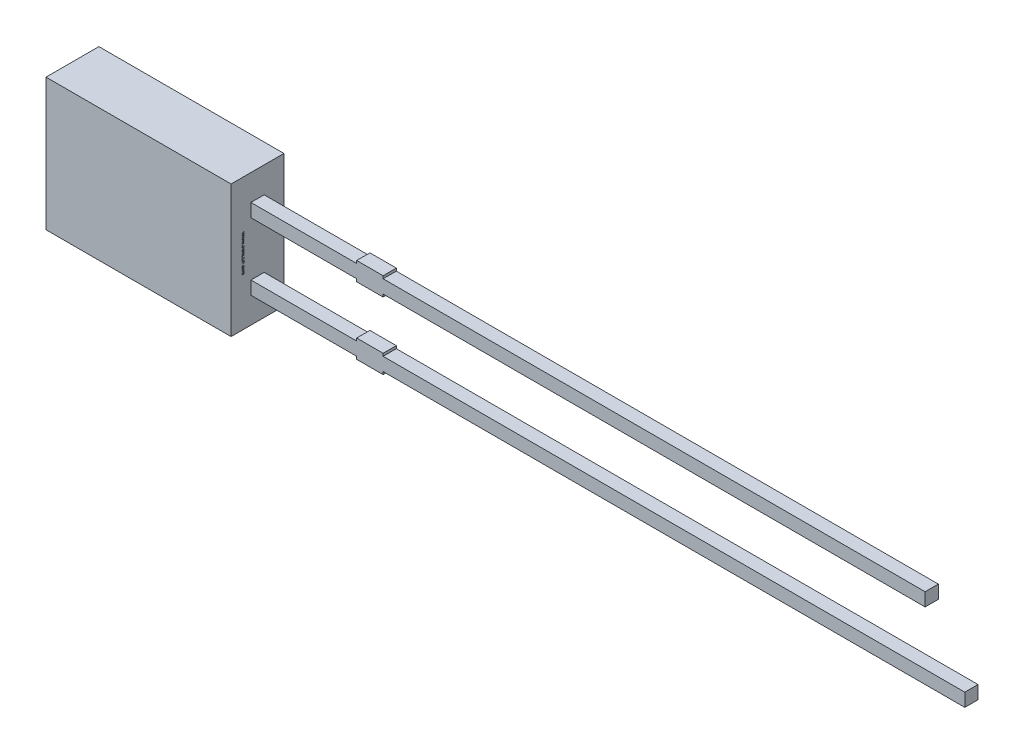
from build123d import *

# Parameters (mm, degrees)
SKETCH1_W          = 7
SKETCH1_H          = 5
EXTRUDE1_DEPTH     = 1
SKETCH1_4_W        = 4
SKETCH1_4_H        = 0.5
SKETCH1_4_W_2      = 1
SKETCH1_4_W_3      = 20.5
SKETCH1_4_H_2      = 0.1
SKETCH1_4_W_4      = 22
EXTRUDE2_DEPTH     = 0.25
SKETCH2_W          = 0.026582279
SKETCH2_H          = 0.025316456
CUT_EXTRUDE1_DEPTH = 0.01


with BuildPart() as part:
    # Sketch1 → Extrude1 (new body, symmetric)
    with BuildSketch(Plane.XY):
        Rectangle(SKETCH1_W, SKETCH1_H)
    extrude(amount=EXTRUDE1_DEPTH, both=True)

    # Sketch1_4 → Extrude2 (add, symmetric)
    with BuildSketch(Plane.XY):
        with Locations((5.5, 1.27)):
            Rectangle(SKETCH1_4_W, SKETCH1_4_H)
        with Locations((8, 1.27)):
            Rectangle(SKETCH1_4_W_2, SKETCH1_4_H)
        with Locations((18.75, 1.27)):
            Rectangle(SKETCH1_4_W_3, SKETCH1_4_H)
        with Locations((8, 1.57)):
            Rectangle(SKETCH1_4_W_2, SKETCH1_4_H_2)
        with Locations((8, 0.97)):
            Rectangle(SKETCH1_4_W_2, SKETCH1_4_H_2)
        with Locations((8, -1.27)):
            Rectangle(SKETCH1_4_W_2, SKETCH1_4_H)
        with Locations((8, -0.97)):
            Rectangle(SKETCH1_4_W_2, SKETCH1_4_H_2)
        with Locations((19.5, -1.27)):
            Rectangle(SKETCH1_4_W_4, SKETCH1_4_H)
        with Locations((5.5, -1.27)):
            Rectangle(SKETCH1_4_W, SKETCH1_4_H)
        with Locations((8, -1.57)):
            Rectangle(SKETCH1_4_W_2, SKETCH1_4_H_2)
    extrude(amount=EXTRUDE2_DEPTH, both=True)

    # Sketch2 → Cut-Extrude1 (cut)
    with BuildSketch(Plane(origin=(3.5, 0, 0), x_dir=(0, 0, -1), z_dir=(1, 0, 0))):
        Polygon((-0.513103718, 0.572151899), (-0.587787263, 0.595609177), (-0.587787263, 0.620352057), (-0.537451029, 0.636768196), (-0.587787263, 0.652294304), (-0.587787263, 0.678026108), (-0.513103718, 0.701265823), (-0.513103718, 0.676087816), (-0.564587104, 0.663093354), (-0.513103718, 0.646677215), (-0.513103718, 0.625178006), (-0.564587104, 0.608860759), (-0.513103718, 0.596044304), align=None)
        Polygon((-0.513103718, 0.437974684), (-0.587787263, 0.461431962), (-0.587787263, 0.486174842), (-0.537451029, 0.502590981), (-0.587787263, 0.518117089), (-0.587787263, 0.543848892), (-0.513103718, 0.567088608), (-0.513103718, 0.541910601), (-0.564587104, 0.528916139), (-0.513103718, 0.5125), (-0.513103718, 0.491000791), (-0.564587104, 0.474683544), (-0.513103718, 0.461867089), align=None)
        Polygon((-0.513103718, 0.303797468), (-0.587787263, 0.327254747), (-0.587787263, 0.351997627), (-0.537451029, 0.368413766), (-0.587787263, 0.383939873), (-0.587787263, 0.409671677), (-0.513103718, 0.432911392), (-0.513103718, 0.407733386), (-0.564587104, 0.394738924), (-0.513103718, 0.378322785), (-0.513103718, 0.356823576), (-0.564587104, 0.340506329), (-0.513103718, 0.327689873), align=None)
        with Locations((-0.574496124, 0.275949367)):
            Rectangle(SKETCH2_W, SKETCH2_H)
        with BuildLine():
            add(Edge.make_bspline(
                [(-0.556616377, 0.159493671), (-0.55783851, 0.159530169), (-0.560238373, 0.15960184), (-0.563746061, 0.160211426), (-0.567070364, 0.161205393), (-0.57023451, 0.162577732), (-0.573203999, 0.164371189), (-0.57600689, 0.16655446), (-0.578611435, 0.169143343), (-0.581047809, 0.172090146), (-0.583229921, 0.175387089), (-0.585135954, 0.178984804), (-0.586730625, 0.18286483), (-0.58806969, 0.187013042), (-0.589058124, 0.191459588), (-0.589782111, 0.196177087), (-0.590255429, 0.201170514), (-0.590297397, 0.204594091), (-0.590318908, 0.206348892)],
                knots=[0, 0, 0, 0, 0.907312236, 1.78165839, 2.635367075, 3.479697475, 4.336364812, 5.205276731, 6.11257575, 7.058770404, 8.040786331, 9.044147278, 10.078219212, 11.153049307, 12.278104542, 13.457648573, 14.696882856, 16, 16, 16, 16], degree=3))
            add(Edge.make_bspline(
                [(-0.590318908, 0.206348892), (-0.590294837, 0.208367148), (-0.590248212, 0.21227633), (-0.589819613, 0.217939855), (-0.589173473, 0.223207892), (-0.588206932, 0.228103607), (-0.587006166, 0.232708206), (-0.585714875, 0.237141474), (-0.584250459, 0.241422786), (-0.583150301, 0.244195876), (-0.582605301, 0.24556962)],
                knots=[0, 0, 0, 0, 1.203215828, 2.33052265, 3.384689099, 4.366106119, 5.303329643, 6.221311756, 7.118865988, 8, 8, 8, 8], degree=3))
            Line((-0.582605301, 0.24556962), (-0.558673339, 0.24556962))
            Line((-0.558673339, 0.24556962), (-0.558673339, 0.242721519))
            add(Edge.make_bspline(
                [(-0.558673339, 0.242721519), (-0.559754794, 0.241356205), (-0.561911355, 0.238633592), (-0.56467396, 0.234200359), (-0.567076123, 0.229552713), (-0.569050124, 0.224707243), (-0.570636449, 0.219810398), (-0.571729976, 0.21493502), (-0.572477325, 0.210169433), (-0.572557831, 0.207010864), (-0.572597389, 0.205458861)],
                knots=[0, 0, 0, 0, 1.030622468, 2.055194264, 3.087043286, 4.125157485, 5.149848264, 6.130935704, 7.081611712, 8, 8, 8, 8], degree=3))
            add(Edge.make_bspline(
                [(-0.572597389, 0.205458861), (-0.572596495, 0.205030082), (-0.57259458, 0.2041121), (-0.572465737, 0.202644063), (-0.572372573, 0.200985464), (-0.572163356, 0.199206598), (-0.571944772, 0.197415781), (-0.571564452, 0.195761121), (-0.571202614, 0.194257482), (-0.570834436, 0.193351), (-0.570659098, 0.192919304)],
                knots=[0, 0, 0, 0, 0.806378557, 1.726393851, 2.771014456, 3.931269413, 5.096090628, 6.161710732, 7.124547685, 8, 8, 8, 8], degree=3))
            add(Edge.make_bspline(
                [(-0.570659098, 0.192919304), (-0.570431274, 0.192439517), (-0.569983552, 0.191496634), (-0.569165945, 0.190201714), (-0.568294644, 0.189019042), (-0.567329225, 0.187957582), (-0.566151316, 0.187107314), (-0.56475046, 0.186479113), (-0.56310016, 0.186136019), (-0.561925149, 0.186096725), (-0.561303877, 0.186075949)],
                knots=[0, 0, 0, 0, 1.024407818, 2.013179384, 2.949802342, 3.859052226, 4.77034807, 5.732977883, 6.801339628, 8, 8, 8, 8], degree=3))
            add(Edge.make_bspline(
                [(-0.561303877, 0.186075949), (-0.560757981, 0.186107391), (-0.559684588, 0.186169215), (-0.558156592, 0.186751006), (-0.556734715, 0.187633905), (-0.555473999, 0.188920927), (-0.554316561, 0.190515003), (-0.553346264, 0.19247074), (-0.552466191, 0.194723719), (-0.552048922, 0.196368178), (-0.551829984, 0.197231013)],
                knots=[0, 0, 0, 0, 0.825212765, 1.622611382, 2.449701629, 3.348069183, 4.336544339, 5.428209675, 6.6506027, 8, 8, 8, 8], degree=3))
            add(Edge.make_bspline(
                [(-0.551829984, 0.197231013), (-0.551382244, 0.19919974), (-0.550465054, 0.203232648), (-0.549317947, 0.209380757), (-0.548051874, 0.215510984), (-0.546842333, 0.219469696), (-0.546252453, 0.221400316)],
                knots=[0, 0, 0, 0, 0.976104583, 1.999535498, 3.024395274, 4, 4, 4, 4], degree=3))
            add(Edge.make_bspline(
                [(-0.546252453, 0.221400316), (-0.54589946, 0.222438832), (-0.545212327, 0.224460401), (-0.544050702, 0.227351945), (-0.54278075, 0.230013057), (-0.541425618, 0.232453168), (-0.53995162, 0.23465249), (-0.538418231, 0.236647679), (-0.536764394, 0.238391205), (-0.535032474, 0.239938889), (-0.533180471, 0.241262203), (-0.531236335, 0.242416954), (-0.529175869, 0.243392589), (-0.527014581, 0.244201473), (-0.524735712, 0.244818545), (-0.522358839, 0.245239801), (-0.519875479, 0.24553819), (-0.518181125, 0.245559001), (-0.517316535, 0.24556962)],
                knots=[0, 0, 0, 0, 1.287286806, 2.505824366, 3.654938963, 4.74627059, 5.778586806, 6.75996495, 7.696030012, 8.595059759, 9.482019644, 10.363222407, 11.245851011, 12.154256429, 13.068444161, 14.012503255, 14.985824751, 16, 16, 16, 16], degree=3))
            add(Edge.make_bspline(
                [(-0.517316535, 0.24556962), (-0.51616039, 0.245532318), (-0.513885118, 0.245458909), (-0.510556074, 0.24485748), (-0.507407337, 0.24383089), (-0.504403874, 0.242444827), (-0.501590788, 0.240616199), (-0.49891224, 0.238431404), (-0.496440649, 0.235807357), (-0.494140315, 0.232830235), (-0.492060917, 0.229542851), (-0.49023036, 0.226003867), (-0.488693709, 0.222234578), (-0.487419815, 0.218249032), (-0.486465144, 0.214030563), (-0.485746212, 0.20959333), (-0.485333031, 0.204919541), (-0.48528178, 0.20172812), (-0.485255617, 0.200098892)],
                knots=[0, 0, 0, 0, 0.894990994, 1.761326291, 2.609044902, 3.454222546, 4.315366365, 5.200560057, 6.125081389, 7.100429509, 8.110379559, 9.133447974, 10.182136699, 11.259192205, 12.370181258, 13.528580438, 14.738335141, 16, 16, 16, 16], degree=3))
            add(Edge.make_bspline(
                [(-0.485255617, 0.200098892), (-0.485277809, 0.198430205), (-0.485322154, 0.19509566), (-0.485700132, 0.190114218), (-0.48625536, 0.185153716), (-0.487097065, 0.180289886), (-0.488073482, 0.175599331), (-0.489169278, 0.171186095), (-0.490407242, 0.167106634), (-0.491361587, 0.16453297), (-0.491822073, 0.163291139)],
                knots=[0, 0, 0, 0, 1.065403572, 2.129000689, 3.188532477, 4.251604565, 5.279552602, 6.247508681, 7.154397237, 8, 8, 8, 8], degree=3))
            Line((-0.491822073, 0.163291139), (-0.514369541, 0.163291139))
            Line((-0.514369541, 0.163291139), (-0.514369541, 0.166119462))
            add(Edge.make_bspline(
                [(-0.514369541, 0.166119462), (-0.513569195, 0.167192367), (-0.511932465, 0.169386485), (-0.509848792, 0.173046122), (-0.507890927, 0.177004358), (-0.506206768, 0.181283188), (-0.504747286, 0.185742216), (-0.503728121, 0.190325174), (-0.503086311, 0.194951338), (-0.503013536, 0.198053049), (-0.502977136, 0.19960443)],
                knots=[0, 0, 0, 0, 0.892283326, 1.824742884, 2.804416662, 3.836872171, 4.8899239, 5.931447339, 6.965372909, 8, 8, 8, 8], degree=3))
            add(Edge.make_bspline(
                [(-0.502977136, 0.19960443), (-0.502998588, 0.200700098), (-0.503041491, 0.202891315), (-0.503432175, 0.206159523), (-0.504063069, 0.209401584), (-0.50488235, 0.211442107), (-0.505291218, 0.212460443)],
                knots=[0, 0, 0, 0, 0.999146175, 1.998183711, 3.000980573, 4, 4, 4, 4], degree=3))
            add(Edge.make_bspline(
                [(-0.505291218, 0.212460443), (-0.505492685, 0.212893946), (-0.505895484, 0.213760664), (-0.506668048, 0.214967308), (-0.507596859, 0.216071977), (-0.508648852, 0.217064055), (-0.509805225, 0.217932452), (-0.511080051, 0.218547803), (-0.512442966, 0.218923676), (-0.513378197, 0.218965835), (-0.513855301, 0.218987342)],
                knots=[0, 0, 0, 0, 1.00524851, 2.009826503, 3.004679593, 4.035271301, 5.048246368, 6.034938417, 6.997532266, 8, 8, 8, 8], degree=3))
            add(Edge.make_bspline(
                [(-0.513855301, 0.218987342), (-0.514493466, 0.218952904), (-0.515712942, 0.218887095), (-0.517428738, 0.218280511), (-0.518907172, 0.217295678), (-0.519902092, 0.216135073), (-0.52059953, 0.215017943), (-0.52111004, 0.213982284), (-0.521593399, 0.212773057), (-0.522090867, 0.211401809), (-0.522582055, 0.209865482), (-0.523057602, 0.208156925), (-0.523506897, 0.206274208), (-0.523793088, 0.204958333), (-0.523942326, 0.204272152)],
                knots=[0, 0, 0, 0, 1.173816843, 2.243057204, 3.312297565, 4.415174738, 5.03266065, 5.73970059, 6.541434878, 7.433956553, 8.430083051, 9.515931566, 10.70464786, 12, 12, 12, 12], degree=3))
            add(Edge.make_bspline(
                [(-0.523942326, 0.204272152), (-0.524318388, 0.202439363), (-0.525057265, 0.198838337), (-0.526160754, 0.193437153), (-0.527435723, 0.18793438), (-0.528584526, 0.184269053), (-0.529183623, 0.182357595)],
                knots=[0, 0, 0, 0, 0.995744513, 1.956417928, 2.934277412, 4, 4, 4, 4], degree=3))
            add(Edge.make_bspline(
                [(-0.529183623, 0.182357595), (-0.529502867, 0.181411041), (-0.53012736, 0.179559428), (-0.531213643, 0.176918797), (-0.532387625, 0.174471738), (-0.533629157, 0.172204706), (-0.534973123, 0.170130736), (-0.53639577, 0.168236053), (-0.537922679, 0.166552235), (-0.539535906, 0.16505467), (-0.541246007, 0.16373551), (-0.543085079, 0.162603212), (-0.545033882, 0.161630984), (-0.547120082, 0.160861379), (-0.549314669, 0.160243358), (-0.551646036, 0.159820261), (-0.554090413, 0.159526278), (-0.55576499, 0.159504661), (-0.556616377, 0.159493671)],
                knots=[0, 0, 0, 0, 1.237467875, 2.420686895, 3.535046182, 4.599015201, 5.620884487, 6.594603852, 7.531477383, 8.433220087, 9.318759595, 10.202828513, 11.105163009, 12.01247538, 12.953896178, 13.926381251, 14.945733412, 16, 16, 16, 16], degree=3))
        make_face()
        with BuildLine():
            Line((-0.587787263, 0.067088608), (-0.587787263, 0.091139241))
            Line((-0.587787263, 0.091139241), (-0.579954984, 0.091139241))
            add(Edge.make_bspline(
                [(-0.579954984, 0.091139241), (-0.580763543, 0.092232549), (-0.582322431, 0.094340433), (-0.584402649, 0.097513458), (-0.586177915, 0.100539548), (-0.587737135, 0.103453039), (-0.588912521, 0.106475242), (-0.589740587, 0.109706756), (-0.59024036, 0.113209581), (-0.590292144, 0.115636475), (-0.590318908, 0.116890823)],
                knots=[0, 0, 0, 0, 1.150872466, 2.218865267, 3.209461834, 4.120482262, 5.012764827, 5.946708227, 6.938749913, 8, 8, 8, 8], degree=3))
            add(Edge.make_bspline(
                [(-0.590318908, 0.116890823), (-0.590296189, 0.117907175), (-0.590251949, 0.119886305), (-0.589907071, 0.122763545), (-0.58936942, 0.125471173), (-0.588561829, 0.127986213), (-0.587596026, 0.130350202), (-0.586316068, 0.132487752), (-0.584885893, 0.134491354), (-0.583178848, 0.136273026), (-0.581281115, 0.137888648), (-0.579148654, 0.139271198), (-0.576815729, 0.140448909), (-0.574263875, 0.141390006), (-0.571505572, 0.142145096), (-0.568526324, 0.142669028), (-0.565339196, 0.142989621), (-0.563144066, 0.14302156), (-0.562015902, 0.143037975)],
                knots=[0, 0, 0, 0, 1.109008058, 2.159558935, 3.158726032, 4.116861086, 5.039058877, 5.938775559, 6.82970133, 7.720510853, 8.624361809, 9.544451588, 10.487360536, 11.471068125, 12.508000841, 13.604731202, 14.768976642, 16, 16, 16, 16], degree=3))
            Line((-0.562015902, 0.143037975), (-0.513103718, 0.143037975))
            Line((-0.513103718, 0.143037975), (-0.513103718, 0.118987342))
            Line((-0.513103718, 0.118987342), (-0.550682832, 0.118987342))
            add(Edge.make_bspline(
                [(-0.550682832, 0.118987342), (-0.551599303, 0.118985706), (-0.553353519, 0.118982576), (-0.555859325, 0.118900237), (-0.558127498, 0.118779336), (-0.560169527, 0.118640631), (-0.562016277, 0.118387615), (-0.563682439, 0.118009906), (-0.56520204, 0.11753908), (-0.566108742, 0.117074761), (-0.566545174, 0.116851266)],
                knots=[0, 0, 0, 0, 1.361401701, 2.605856924, 3.723918663, 4.735739235, 5.645738665, 6.489217889, 7.27279937, 8, 8, 8, 8], degree=3))
            add(Edge.make_bspline(
                [(-0.566545174, 0.116851266), (-0.566943889, 0.116621259), (-0.567727728, 0.116169086), (-0.568733906, 0.115248796), (-0.569578174, 0.114170053), (-0.570234203, 0.112892449), (-0.570733151, 0.111405901), (-0.571073388, 0.109677971), (-0.57128889, 0.107692609), (-0.571316798, 0.106283591), (-0.571331566, 0.105537975)],
                knots=[0, 0, 0, 0, 0.849138082, 1.669332372, 2.503455908, 3.370611167, 4.311442699, 5.394692208, 6.621337967, 8, 8, 8, 8], degree=3))
            add(Edge.make_bspline(
                [(-0.571331566, 0.105537975), (-0.571314209, 0.104996691), (-0.571278522, 0.103883773), (-0.571046076, 0.102172461), (-0.570689401, 0.100375884), (-0.570029546, 0.097861301), (-0.568843367, 0.094694674), (-0.567488959, 0.092335372), (-0.566802294, 0.091139241)],
                knots=[0, 0, 0, 0, 0.638127216, 1.312033637, 2.033062677, 2.79661882, 4.375931797, 6, 6, 6, 6], degree=3))
            Line((-0.566802294, 0.091139241), (-0.513103718, 0.091139241))
            Line((-0.513103718, 0.091139241), (-0.513103718, 0.067088608))
            Line((-0.513103718, 0.067088608), (-0.587787263, 0.067088608))
        make_face()
        with BuildLine():
            Line((-0.587787263, -0.030379747), (-0.587787263, -0.006329114))
            Line((-0.587787263, -0.006329114), (-0.550208149, -0.006329114))
            add(Edge.make_bspline(
                [(-0.550208149, -0.006329114), (-0.548678106, -0.0063046), (-0.545627081, -0.006255716), (-0.54186467, -0.005973592), (-0.539022346, -0.00559507), (-0.537184465, -0.005225415), (-0.535636325, -0.004793715), (-0.534750566, -0.004381435), (-0.534345807, -0.004193038)],
                knots=[0, 0, 0, 0, 1.709124929, 3.408128882, 4.211124727, 4.91016634, 5.501986363, 6, 6, 6, 6], degree=3))
            add(Edge.make_bspline(
                [(-0.534345807, -0.004193038), (-0.533947754, -0.003948575), (-0.533167314, -0.003469272), (-0.532154301, -0.002531948), (-0.53132546, -0.001438061), (-0.530643909, -0.000167292), (-0.530173329, 0.001323905), (-0.529780099, 0.003040645), (-0.52961319, 0.005027263), (-0.52957803, 0.006434533), (-0.529559415, 0.007179589)],
                knots=[0, 0, 0, 0, 0.86006424, 1.686277094, 2.52783008, 3.38194165, 4.331801563, 5.402842185, 6.624978739, 8, 8, 8, 8], degree=3))
            add(Edge.make_bspline(
                [(-0.529559415, 0.007179589), (-0.529616152, 0.00831141), (-0.529732005, 0.010622505), (-0.530443513, 0.013484698), (-0.531262472, 0.015815302), (-0.532021303, 0.017667827), (-0.532992744, 0.019576457), (-0.533714567, 0.020855869), (-0.534088687, 0.021518987)],
                knots=[0, 0, 0, 0, 1.338371478, 2.732853438, 3.468019217, 4.261884641, 5.099136535, 6, 6, 6, 6], degree=3))
            Line((-0.534088687, 0.021518987), (-0.587787263, 0.021518987))
            Line((-0.587787263, 0.021518987), (-0.587787263, 0.04556962))
            Line((-0.587787263, 0.04556962), (-0.513103718, 0.04556962))
            Line((-0.513103718, 0.04556962), (-0.513103718, 0.021518987))
            Line((-0.513103718, 0.021518987), (-0.520935997, 0.021518987))
            add(Edge.make_bspline(
                [(-0.520935997, 0.021518987), (-0.520129845, 0.020461581), (-0.518560623, 0.018403276), (-0.516520203, 0.015224038), (-0.514721433, 0.01214014), (-0.513208617, 0.009087131), (-0.512001842, 0.005972176), (-0.511190853, 0.002709417), (-0.51064705, -0.000706989), (-0.510597356, -0.003043704), (-0.510572073, -0.004232595)],
                knots=[0, 0, 0, 0, 1.126119141, 2.192057864, 3.198061997, 4.149848529, 5.076251285, 6.021887753, 6.99356175, 8, 8, 8, 8], degree=3))
            add(Edge.make_bspline(
                [(-0.510572073, -0.004232595), (-0.510597462, -0.005228866), (-0.510647026, -0.007173765), (-0.510956735, -0.010008526), (-0.5115074, -0.012679947), (-0.512305229, -0.015172221), (-0.513290841, -0.017514841), (-0.514522356, -0.019676785), (-0.515980779, -0.021668856), (-0.517641782, -0.023497257), (-0.519531508, -0.025128075), (-0.521648772, -0.026545111), (-0.523991869, -0.027725092), (-0.526552178, -0.028695805), (-0.529317287, -0.029470228), (-0.532313252, -0.029985359), (-0.535517431, -0.030339143), (-0.537733474, -0.030365941), (-0.538875079, -0.030379747)],
                knots=[0, 0, 0, 0, 1.08848837, 2.124922927, 3.110950502, 4.063144162, 4.979605775, 5.882838355, 6.774625441, 7.671951181, 8.57587277, 9.494821853, 10.448322275, 11.435533005, 12.482327682, 13.580118324, 14.753386918, 16, 16, 16, 16], degree=3))
            Line((-0.538875079, -0.030379747), (-0.587787263, -0.030379747))
        make_face()
        Polygon((-0.587787263, -0.125316456), (-0.587787263, -0.053164557), (-0.487787263, -0.053164557), (-0.487787263, -0.078481013), (-0.568799921, -0.078481013), (-0.568799921, -0.125316456), align=None)
        Polygon((-0.587787263, -0.212658228), (-0.587787263, -0.140506329), (-0.487787263, -0.140506329), (-0.487787263, -0.212658228), (-0.506774604, -0.212658228), (-0.506774604, -0.165822785), (-0.524496123, -0.165822785), (-0.524496123, -0.208860759), (-0.543483465, -0.208860759), (-0.543483465, -0.165822785), (-0.568799921, -0.165822785), (-0.568799921, -0.212658228), align=None)
        with BuildLine():
            add(Edge.make_bspline(
                [(-0.537886155, -0.329113924), (-0.539033844, -0.329094609), (-0.54130673, -0.329056357), (-0.544671537, -0.328761165), (-0.547937212, -0.32823514), (-0.551121461, -0.327555959), (-0.554200388, -0.326633453), (-0.557207965, -0.325551739), (-0.560113459, -0.324242093), (-0.562914893, -0.322737241), (-0.565586996, -0.321087768), (-0.568107205, -0.319313019), (-0.570490423, -0.31746724), (-0.572685317, -0.315477927), (-0.574727336, -0.313398746), (-0.576618151, -0.311223217), (-0.578321581, -0.308918153), (-0.579344466, -0.30731099), (-0.579856092, -0.30650712)],
                knots=[0, 0, 0, 0, 1.105570398, 2.18947457, 3.250358341, 4.290584537, 5.323553275, 6.344225964, 7.367641686, 8.3905646, 9.405808457, 10.390761353, 11.358902336, 12.307789878, 13.241960776, 14.165076779, 15.082208636, 16, 16, 16, 16], degree=3))
            add(Edge.make_bspline(
                [(-0.579856092, -0.30650712), (-0.580568231, -0.305267892), (-0.581996144, -0.302783112), (-0.583664734, -0.298799278), (-0.58506885, -0.294673795), (-0.586123275, -0.290323409), (-0.586850319, -0.285676399), (-0.587411125, -0.28067499), (-0.587712885, -0.275267401), (-0.587761905, -0.271532506), (-0.587787263, -0.269600475)],
                knots=[0, 0, 0, 0, 0.896288622, 1.797150563, 2.705281913, 3.629615989, 4.602417572, 5.655716007, 6.787320449, 8, 8, 8, 8], degree=3))
            Line((-0.587787263, -0.269600475), (-0.587787263, -0.234177215))
            Line((-0.587787263, -0.234177215), (-0.487787263, -0.234177215))
            Line((-0.487787263, -0.234177215), (-0.487787263, -0.270609177))
            add(Edge.make_bspline(
                [(-0.487787263, -0.270609177), (-0.487803874, -0.272587909), (-0.487835914, -0.276404637), (-0.488253505, -0.281921476), (-0.488850329, -0.287026684), (-0.4897752, -0.291712032), (-0.490890545, -0.296012037), (-0.492249673, -0.299937513), (-0.493748381, -0.303549287), (-0.495022074, -0.305728129), (-0.49563932, -0.306784019)],
                knots=[0, 0, 0, 0, 1.267175336, 2.444223962, 3.542125549, 4.557526608, 5.500936977, 6.385043188, 7.217374394, 8, 8, 8, 8], degree=3))
            add(Edge.make_bspline(
                [(-0.49563932, -0.306784019), (-0.49617586, -0.307634972), (-0.497242774, -0.309327097), (-0.499024626, -0.311728312), (-0.500980703, -0.313957739), (-0.503032522, -0.316086242), (-0.505235409, -0.318066059), (-0.507574116, -0.319909259), (-0.51005221, -0.321613076), (-0.512661679, -0.323171039), (-0.515391731, -0.324591854), (-0.51826479, -0.32578116), (-0.52124332, -0.326830509), (-0.524352282, -0.327636046), (-0.527560119, -0.32833396), (-0.530901463, -0.328768694), (-0.534353951, -0.329055305), (-0.536698841, -0.32909422), (-0.537886155, -0.329113924)],
                knots=[0, 0, 0, 0, 0.964065863, 1.917049184, 2.86229036, 3.805247319, 4.749389377, 5.698846072, 6.657678277, 7.629829384, 8.610569287, 9.604676042, 10.607940105, 11.6349849, 12.681042988, 13.752616828, 14.862056989, 16, 16, 16, 16], degree=3))
        make_face()
        with BuildLine():
            add(Edge.make_bspline(
                [(-0.537727927, -0.302531646), (-0.536923167, -0.302521405), (-0.535344583, -0.302501317), (-0.533029069, -0.30230975), (-0.530799419, -0.302050694), (-0.528664727, -0.30161964), (-0.526605156, -0.301119993), (-0.524647662, -0.300477843), (-0.522768089, -0.299753447), (-0.5209906, -0.298871809), (-0.519282218, -0.297898172), (-0.517696702, -0.296750679), (-0.516183816, -0.295502341), (-0.514755832, -0.294124054), (-0.513449936, -0.292581114), (-0.512219859, -0.290921012), (-0.511091533, -0.289120654), (-0.510431484, -0.287847665), (-0.510097389, -0.287203323)],
                knots=[0, 0, 0, 0, 1.152093354, 2.259898929, 3.325467225, 4.364140538, 5.376172865, 6.358396836, 7.312077728, 8.257828931, 9.196960457, 10.124297759, 11.056236784, 12.004246951, 12.961658638, 13.947279359, 14.960983522, 16, 16, 16, 16], degree=3))
            add(Edge.make_bspline(
                [(-0.510097389, -0.287203323), (-0.509790677, -0.286528425), (-0.509182753, -0.285190731), (-0.50845156, -0.283119908), (-0.507878725, -0.281030524), (-0.507447866, -0.278828925), (-0.507125936, -0.276359165), (-0.506928677, -0.273433583), (-0.506786508, -0.269977674), (-0.506778756, -0.267490959), (-0.506774604, -0.266159019)],
                knots=[0, 0, 0, 0, 0.826967603, 1.639107464, 2.447640171, 3.242670507, 4.14065217, 5.225198036, 6.513753944, 8, 8, 8, 8], degree=3))
            Line((-0.506774604, -0.266159019), (-0.506774604, -0.259493671))
            Line((-0.506774604, -0.259493671), (-0.568799921, -0.259493671))
            Line((-0.568799921, -0.259493671), (-0.568799921, -0.266159019))
            add(Edge.make_bspline(
                [(-0.568799921, -0.266159019), (-0.568795171, -0.266917226), (-0.568786002, -0.268380991), (-0.568742939, -0.270497235), (-0.568696052, -0.272463031), (-0.56857959, -0.274267902), (-0.568506944, -0.275926587), (-0.568328565, -0.277413368), (-0.568186385, -0.278755857), (-0.567918662, -0.280323454), (-0.567502479, -0.28217662), (-0.5668243, -0.28433788), (-0.565973904, -0.286478414), (-0.565288937, -0.287866987), (-0.564943117, -0.288568038)],
                knots=[0, 0, 0, 0, 1.186793418, 2.291178421, 3.313283093, 4.264083014, 5.122158624, 5.910777728, 6.607099052, 7.234812932, 8.398911528, 9.577194775, 10.776795607, 12, 12, 12, 12], degree=3))
            add(Edge.make_bspline(
                [(-0.564943117, -0.288568038), (-0.564601601, -0.289153154), (-0.563928086, -0.29030708), (-0.562794013, -0.291930584), (-0.561586288, -0.293438302), (-0.560297837, -0.294834314), (-0.558909595, -0.296097614), (-0.557443054, -0.297249633), (-0.555895075, -0.298280082), (-0.553701558, -0.299515471), (-0.550670621, -0.300738716), (-0.546703235, -0.301778259), (-0.542343471, -0.30241513), (-0.539305854, -0.302491812), (-0.537727927, -0.302531646)],
                knots=[0, 0, 0, 0, 0.755160452, 1.489275589, 2.205657296, 2.907868421, 3.605098304, 4.296256403, 4.985378686, 5.676536785, 7.100390329, 8.614249252, 10.241231541, 12, 12, 12, 12], degree=3))
        make_face(mode=Mode.SUBTRACT)
        with Locations((-0.574496124, -0.360759494)):
            Rectangle(SKETCH2_W, SKETCH2_H)
        with BuildLine():
            add(Edge.make_bspline(
                [(-0.590318908, -0.435403481), (-0.590297097, -0.433813368), (-0.590254285, -0.430692232), (-0.589777368, -0.42612089), (-0.589059673, -0.421755717), (-0.588038767, -0.417609409), (-0.58669127, -0.413695618), (-0.585038335, -0.41003198), (-0.58305315, -0.406625123), (-0.581473941, -0.404566476), (-0.580686788, -0.403540348)],
                knots=[0, 0, 0, 0, 1.123670284, 2.205584497, 3.245308791, 4.249063313, 5.220352711, 6.167273909, 7.086481357, 8, 8, 8, 8], degree=3))
            add(Edge.make_bspline(
                [(-0.580686788, -0.403540348), (-0.579832014, -0.402588601), (-0.578125771, -0.400688786), (-0.575154344, -0.398222853), (-0.5718713, -0.396099767), (-0.568269078, -0.394314215), (-0.564352349, -0.392883291), (-0.560107686, -0.391860157), (-0.555546906, -0.391240912), (-0.552398972, -0.391173746), (-0.550781725, -0.391139241)],
                knots=[0, 0, 0, 0, 0.916457077, 1.82937027, 2.759194969, 3.714948755, 4.706655623, 5.743329475, 6.840637961, 8, 8, 8, 8], degree=3))
            add(Edge.make_bspline(
                [(-0.550781725, -0.391139241), (-0.549078498, -0.391178001), (-0.545777417, -0.391253124), (-0.54100523, -0.391916883), (-0.536587549, -0.392986496), (-0.532535641, -0.394524054), (-0.52884245, -0.396454496), (-0.525470615, -0.398718989), (-0.522427691, -0.401339514), (-0.520682251, -0.403346653), (-0.519808623, -0.404351266)],
                knots=[0, 0, 0, 0, 1.171797512, 2.271099083, 3.308930235, 4.294129479, 5.24602549, 6.17106565, 7.084581485, 8, 8, 8, 8], degree=3))
            add(Edge.make_bspline(
                [(-0.519808623, -0.404351266), (-0.519040037, -0.405377136), (-0.517493581, -0.407441268), (-0.515592881, -0.410844773), (-0.513998096, -0.414467988), (-0.512750451, -0.418297559), (-0.511796545, -0.422270367), (-0.511072702, -0.426330027), (-0.510652144, -0.43047628), (-0.510598892, -0.43326648), (-0.510572073, -0.434671677)],
                knots=[0, 0, 0, 0, 0.952130878, 1.915761808, 2.890227217, 3.891541892, 4.905612075, 5.925811839, 6.955400088, 8, 8, 8, 8], degree=3))
            add(Edge.make_bspline(
                [(-0.510572073, -0.434671677), (-0.510589075, -0.435918396), (-0.510622507, -0.438369867), (-0.510944617, -0.441970914), (-0.511477736, -0.445425455), (-0.512216338, -0.448730387), (-0.513107941, -0.451904334), (-0.514147083, -0.454954511), (-0.515280351, -0.457914321), (-0.516164886, -0.45981489), (-0.51660451, -0.460759494)],
                knots=[0, 0, 0, 0, 1.107648782, 2.178012834, 3.209595929, 4.211695017, 5.185427128, 6.137685403, 7.07440854, 8, 8, 8, 8], degree=3))
            Line((-0.51660451, -0.460759494), (-0.537154351, -0.460759494))
            Line((-0.537154351, -0.460759494), (-0.537154351, -0.45741693))
            add(Edge.make_bspline(
                [(-0.537154351, -0.45741693), (-0.536737131, -0.456917386), (-0.535835417, -0.45583775), (-0.534414665, -0.454051335), (-0.532885071, -0.451902393), (-0.531993125, -0.450248857), (-0.531517484, -0.449367089)],
                knots=[0, 0, 0, 0, 0.792826818, 1.713491785, 2.780691913, 4, 4, 4, 4], degree=3))
            add(Edge.make_bspline(
                [(-0.531517484, -0.449367089), (-0.531075526, -0.448439154), (-0.530169666, -0.446537209), (-0.529336833, -0.443981204), (-0.528769106, -0.441789202), (-0.528512685, -0.439971666), (-0.528323123, -0.438038046), (-0.528303617, -0.436702803), (-0.528293592, -0.436016614)],
                knots=[0, 0, 0, 0, 1.332524827, 2.731214173, 3.480270227, 4.267952375, 5.109889624, 6, 6, 6, 6], degree=3))
            add(Edge.make_bspline(
                [(-0.528293592, -0.436016614), (-0.528313141, -0.435251058), (-0.528351028, -0.433767448), (-0.528628083, -0.431605939), (-0.529106342, -0.429587528), (-0.529746442, -0.427684306), (-0.530634055, -0.425946243), (-0.531667692, -0.424319403), (-0.532893493, -0.422827143), (-0.534334436, -0.421507882), (-0.535914365, -0.420315156), (-0.53764848, -0.419295954), (-0.539495079, -0.418383498), (-0.541499528, -0.41768856), (-0.543628304, -0.417128822), (-0.545891424, -0.416739892), (-0.548290934, -0.416497934), (-0.549937242, -0.416470016), (-0.550781725, -0.416455696)],
                knots=[0, 0, 0, 0, 1.087302107, 2.107140881, 3.088415001, 4.030197574, 4.951552271, 5.852940509, 6.764198256, 7.685219758, 8.621679636, 9.570836121, 10.538340132, 11.542450476, 12.578202196, 13.66207107, 14.800746211, 16, 16, 16, 16], degree=3))
            add(Edge.make_bspline(
                [(-0.550781725, -0.416455696), (-0.551645881, -0.416470471), (-0.553324894, -0.416499177), (-0.555766505, -0.416732691), (-0.558047936, -0.417148582), (-0.560173256, -0.41771983), (-0.562139274, -0.418444178), (-0.563936671, -0.419349295), (-0.565593478, -0.420385652), (-0.56705609, -0.42163021), (-0.568372411, -0.422994093), (-0.569508546, -0.424508985), (-0.570456691, -0.426168224), (-0.571261154, -0.427950405), (-0.571839552, -0.429883445), (-0.572276244, -0.431939982), (-0.572564801, -0.434129537), (-0.572586363, -0.435639891), (-0.572597389, -0.436412184)],
                knots=[0, 0, 0, 0, 1.230336593, 2.390482092, 3.487897344, 4.52859895, 5.520747884, 6.465347575, 7.38981449, 8.296085817, 9.192433006, 10.084246191, 10.984321635, 11.908883871, 12.862027947, 13.850751296, 14.901019963, 16, 16, 16, 16], degree=3))
            add(Edge.make_bspline(
                [(-0.572597389, -0.436412184), (-0.572589262, -0.437138038), (-0.572573417, -0.438553063), (-0.57235534, -0.44061781), (-0.572079458, -0.442578718), (-0.57164005, -0.444414258), (-0.571097675, -0.446109524), (-0.570531169, -0.447669947), (-0.569926384, -0.449082395), (-0.56945883, -0.449943749), (-0.569235048, -0.450356013)],
                knots=[0, 0, 0, 0, 1.200823684, 2.340960236, 3.433630075, 4.476504061, 5.46014544, 6.378484521, 7.223905657, 8, 8, 8, 8], degree=3))
            add(Edge.make_bspline(
                [(-0.569235048, -0.450356013), (-0.568805153, -0.451056218), (-0.567973511, -0.452410785), (-0.566571945, -0.454249513), (-0.565157685, -0.455894382), (-0.564201468, -0.456918894), (-0.56373663, -0.45741693)],
                knots=[0, 0, 0, 0, 1.098601379, 2.125273733, 3.088655601, 4, 4, 4, 4], degree=3))
            Line((-0.56373663, -0.45741693), (-0.56373663, -0.460759494))
            Line((-0.56373663, -0.460759494), (-0.584444699, -0.460759494))
            add(Edge.make_bspline(
                [(-0.584444699, -0.460759494), (-0.584882194, -0.459814104), (-0.585757287, -0.457923097), (-0.586911159, -0.455008518), (-0.587879319, -0.452020545), (-0.5887824, -0.448972172), (-0.589470762, -0.445800089), (-0.589963885, -0.442477058), (-0.590264797, -0.43899556), (-0.590300625, -0.436617171), (-0.590318908, -0.435403481)],
                knots=[0, 0, 0, 0, 0.952012952, 1.904254716, 2.862729541, 3.822037426, 4.808956931, 5.82647221, 6.890850784, 8, 8, 8, 8], degree=3))
        make_face()
        with BuildLine():
            add(Edge.make_bspline(
                [(-0.550485048, -0.553164557), (-0.551989954, -0.553139862), (-0.554923419, -0.553091723), (-0.559195211, -0.552552407), (-0.563231208, -0.551739627), (-0.567018417, -0.550567096), (-0.570575691, -0.549086703), (-0.573865484, -0.547235764), (-0.576918714, -0.545064759), (-0.579708598, -0.542573722), (-0.582207109, -0.53977252), (-0.584402362, -0.536698338), (-0.586215804, -0.533324511), (-0.587727894, -0.5297102), (-0.588897129, -0.525825548), (-0.589709846, -0.521671329), (-0.590245317, -0.517254195), (-0.590293969, -0.514215776), (-0.590318908, -0.512658228)],
                knots=[0, 0, 0, 0, 1.120167703, 2.183507516, 3.201345984, 4.182878364, 5.131270247, 6.065524964, 6.98789854, 7.91635504, 8.84481154, 9.778033504, 10.722808862, 11.691211189, 12.691525459, 13.738229926, 14.840575679, 16, 16, 16, 16], degree=3))
            add(Edge.make_bspline(
                [(-0.590318908, -0.512658228), (-0.590293886, -0.511100707), (-0.590245074, -0.508062341), (-0.589710743, -0.503644832), (-0.588892792, -0.499485737), (-0.587736691, -0.49559643), (-0.586210141, -0.491987684), (-0.584403094, -0.488617817), (-0.5822069, -0.485544052), (-0.579708708, -0.482742566), (-0.576918482, -0.480252248), (-0.573866299, -0.478078657), (-0.570570345, -0.476236243), (-0.567027299, -0.474718389), (-0.563226462, -0.473585065), (-0.55919602, -0.472761602), (-0.5549232, -0.472225394), (-0.551989879, -0.472176819), (-0.550485048, -0.472151899)],
                knots=[0, 0, 0, 0, 1.15937715, 2.261678054, 3.308339936, 4.313313916, 5.277148057, 6.221884977, 7.155068972, 8.083487698, 9.011906424, 9.934242473, 10.868459181, 11.818729666, 12.798784262, 13.81658132, 14.879877871, 16, 16, 16, 16], degree=3))
            add(Edge.make_bspline(
                [(-0.550485048, -0.472151899), (-0.548973624, -0.472177022), (-0.546020613, -0.472226107), (-0.541721741, -0.472761477), (-0.53766109, -0.473579494), (-0.533852777, -0.474739526), (-0.530301177, -0.476255799), (-0.526999072, -0.478096824), (-0.523952498, -0.480293292), (-0.521162746, -0.48280279), (-0.518666365, -0.485614584), (-0.516493459, -0.488708516), (-0.514656802, -0.492060435), (-0.513134969, -0.495667634), (-0.512000404, -0.49955419), (-0.511182825, -0.503691132), (-0.510644753, -0.508088526), (-0.51059674, -0.511107264), (-0.510572073, -0.512658228)],
                knots=[0, 0, 0, 0, 1.124034801, 2.196132384, 3.217834281, 4.203147447, 5.152578239, 6.085969439, 7.010345409, 7.941219594, 8.872481455, 9.802010446, 10.748267785, 11.711250247, 12.709230373, 13.754967386, 14.846549946, 16, 16, 16, 16], degree=3))
            add(Edge.make_bspline(
                [(-0.510572073, -0.512658228), (-0.510596795, -0.514228966), (-0.510644927, -0.51728713), (-0.51118113, -0.521730542), (-0.511994135, -0.525904381), (-0.513160531, -0.529803006), (-0.514671945, -0.533428756), (-0.516506603, -0.536788831), (-0.518708661, -0.539860139), (-0.521215817, -0.542647393), (-0.524021218, -0.545127634), (-0.527070842, -0.54729655), (-0.530390558, -0.549103768), (-0.533945426, -0.550585538), (-0.537739195, -0.551757711), (-0.541773301, -0.552578696), (-0.546048298, -0.553084687), (-0.548980428, -0.553137471), (-0.550485048, -0.553164557)],
                knots=[0, 0, 0, 0, 1.167358552, 2.272800965, 3.322628764, 4.326027541, 5.29287265, 6.238482395, 7.166210353, 8.096447471, 9.020151799, 9.945039072, 10.873038967, 11.824425184, 12.804379233, 13.820580988, 14.881633558, 16, 16, 16, 16], degree=3))
        make_face()
        with BuildLine():
            add(Edge.make_bspline(
                [(-0.568977927, -0.523457278), (-0.568477921, -0.523812456), (-0.567460348, -0.524535285), (-0.565759925, -0.525405537), (-0.563938131, -0.526193542), (-0.561908849, -0.526811737), (-0.559606404, -0.527291059), (-0.556952811, -0.52760245), (-0.553917299, -0.527832094), (-0.551764586, -0.527842556), (-0.550623497, -0.527848101)],
                knots=[0, 0, 0, 0, 0.764956307, 1.556776596, 2.379454426, 3.241401993, 4.200532455, 5.312591107, 6.575484591, 8, 8, 8, 8], degree=3))
            add(Edge.make_bspline(
                [(-0.550623497, -0.527848101), (-0.549548615, -0.527830412), (-0.547489259, -0.527796522), (-0.544529496, -0.527610152), (-0.54184607, -0.527261478), (-0.539428673, -0.5267636), (-0.537257986, -0.526153829), (-0.535315623, -0.525427894), (-0.533597021, -0.524589376), (-0.532591789, -0.523903909), (-0.532110839, -0.523575949)],
                knots=[0, 0, 0, 0, 1.337076348, 2.561692668, 3.686680134, 4.69989255, 5.629188848, 6.488203485, 7.276684665, 8, 8, 8, 8], degree=3))
            add(Edge.make_bspline(
                [(-0.532110839, -0.523575949), (-0.531671556, -0.523238652), (-0.530809799, -0.522576962), (-0.529727615, -0.521400911), (-0.52882932, -0.520136352), (-0.52816928, -0.51875605), (-0.527650022, -0.517310883), (-0.527303186, -0.515802557), (-0.527075064, -0.514247405), (-0.527043686, -0.513193069), (-0.527027769, -0.512658228)],
                knots=[0, 0, 0, 0, 1.058684453, 2.076859345, 3.046867319, 4.017860406, 4.996047344, 5.981941452, 6.976284511, 8, 8, 8, 8], degree=3))
            add(Edge.make_bspline(
                [(-0.527027769, -0.512658228), (-0.527038715, -0.512130296), (-0.527060126, -0.511097679), (-0.527239808, -0.509595013), (-0.527534398, -0.508184065), (-0.527952331, -0.506844191), (-0.528547813, -0.505552217), (-0.529404238, -0.504317872), (-0.530479569, -0.503101936), (-0.531330087, -0.502363688), (-0.531774604, -0.501977848)],
                knots=[0, 0, 0, 0, 1.041978199, 2.038073998, 2.982578265, 3.884042198, 4.804014415, 5.778706634, 6.839057036, 8, 8, 8, 8], degree=3))
            add(Edge.make_bspline(
                [(-0.531774604, -0.501977848), (-0.53224923, -0.501644363), (-0.533247831, -0.500942719), (-0.534952351, -0.500059744), (-0.536914271, -0.49932839), (-0.539098013, -0.49863615), (-0.541569161, -0.498117886), (-0.544322439, -0.497717147), (-0.547376866, -0.497516433), (-0.549509083, -0.497484858), (-0.550623497, -0.497468354)],
                knots=[0, 0, 0, 0, 0.706185926, 1.485796665, 2.33004681, 3.254820698, 4.274138656, 5.402098861, 6.642194297, 8, 8, 8, 8], degree=3))
            add(Edge.make_bspline(
                [(-0.550623497, -0.497468354), (-0.551625961, -0.497477501), (-0.553567073, -0.497495212), (-0.556373458, -0.497694126), (-0.558977391, -0.498022802), (-0.561367423, -0.498499446), (-0.56355232, -0.49907369), (-0.565503979, -0.499821164), (-0.567259037, -0.500644638), (-0.568286778, -0.501344976), (-0.568780142, -0.501681171)],
                knots=[0, 0, 0, 0, 1.270915159, 2.460926195, 3.565223763, 4.596447547, 5.549594966, 6.425286377, 7.244063354, 8, 8, 8, 8], degree=3))
            add(Edge.make_bspline(
                [(-0.568780142, -0.501681171), (-0.569196628, -0.502021731), (-0.570017756, -0.502693168), (-0.571101772, -0.503842086), (-0.571963123, -0.505125798), (-0.572693611, -0.506477001), (-0.573222857, -0.507938804), (-0.573599463, -0.509490696), (-0.573815217, -0.511142431), (-0.573846945, -0.512275225), (-0.573863212, -0.512856013)],
                knots=[0, 0, 0, 0, 1.011121112, 1.993489184, 2.956264801, 3.910060304, 4.874908638, 5.87009835, 6.907993364, 8, 8, 8, 8], degree=3))
            add(Edge.make_bspline(
                [(-0.573863212, -0.512856013), (-0.57380963, -0.513856962), (-0.573702707, -0.515854325), (-0.572991056, -0.518269474), (-0.572141776, -0.520076797), (-0.571262521, -0.521316068), (-0.570222982, -0.522472259), (-0.569397004, -0.523125727), (-0.568977927, -0.523457278)],
                knots=[0, 0, 0, 0, 1.48399549, 2.96126462, 3.700919455, 4.439278468, 5.208134679, 6, 6, 6, 6], degree=3))
        make_face(mode=Mode.SUBTRACT)
        with BuildLine():
            Line((-0.534088687, -0.644303797), (-0.587787263, -0.644303797))
            Line((-0.587787263, -0.644303797), (-0.587787263, -0.620253165))
            Line((-0.587787263, -0.620253165), (-0.54993125, -0.620253165))
            add(Edge.make_bspline(
                [(-0.54993125, -0.620253165), (-0.549041216, -0.620247698), (-0.547333584, -0.62023721), (-0.54487397, -0.620204186), (-0.542625366, -0.620123915), (-0.540579167, -0.620016376), (-0.538719702, -0.619829431), (-0.537044866, -0.619518092), (-0.535539341, -0.619096595), (-0.534638393, -0.618688245), (-0.534207358, -0.61849288)],
                knots=[0, 0, 0, 0, 1.339742217, 2.570446543, 3.702449567, 4.726327994, 5.654556215, 6.512888379, 7.288529137, 8, 8, 8, 8], degree=3))
            add(Edge.make_bspline(
                [(-0.534207358, -0.61849288), (-0.533821991, -0.618282954), (-0.533058097, -0.61786683), (-0.532090236, -0.616998785), (-0.531279591, -0.615990476), (-0.530638137, -0.614810314), (-0.530139975, -0.613431631), (-0.529790629, -0.611816509), (-0.529610227, -0.609952652), (-0.52957699, -0.608630364), (-0.529559415, -0.607931171)],
                knots=[0, 0, 0, 0, 0.859345536, 1.703436662, 2.532498256, 3.390183975, 4.328249457, 5.402602062, 6.626559876, 8, 8, 8, 8], degree=3))
            add(Edge.make_bspline(
                [(-0.529559415, -0.607931171), (-0.529582977, -0.607343877), (-0.529630314, -0.60616399), (-0.529871853, -0.604405516), (-0.530373799, -0.602686303), (-0.531210437, -0.600467627), (-0.532426904, -0.597858323), (-0.533548793, -0.595885907), (-0.534088687, -0.594936709)],
                knots=[0, 0, 0, 0, 0.759443456, 1.525737455, 2.286422378, 3.068189154, 4.58910569, 6, 6, 6, 6], degree=3))
            Line((-0.534088687, -0.594936709), (-0.587787263, -0.594936709))
            Line((-0.587787263, -0.594936709), (-0.587787263, -0.570886076))
            Line((-0.587787263, -0.570886076), (-0.513103718, -0.570886076))
            Line((-0.513103718, -0.570886076), (-0.513103718, -0.594936709))
            Line((-0.513103718, -0.594936709), (-0.520935997, -0.594936709))
            add(Edge.make_bspline(
                [(-0.520935997, -0.594936709), (-0.520154515, -0.595957746), (-0.518637194, -0.597940187), (-0.516591258, -0.60095416), (-0.514827823, -0.603909643), (-0.513297265, -0.606810759), (-0.512041884, -0.609757207), (-0.511205118, -0.612851706), (-0.510672799, -0.616094453), (-0.510606057, -0.618312736), (-0.510572073, -0.619442247)],
                knots=[0, 0, 0, 0, 1.136140478, 2.205924536, 3.217129804, 4.176128364, 5.103417168, 6.04061054, 7.002313223, 8, 8, 8, 8], degree=3))
            add(Edge.make_bspline(
                [(-0.510572073, -0.619442247), (-0.510603818, -0.62064549), (-0.510665862, -0.622997145), (-0.511335124, -0.626409066), (-0.512339749, -0.629624954), (-0.513830181, -0.632580961), (-0.515662982, -0.635303105), (-0.51794069, -0.637694085), (-0.520586496, -0.639808625), (-0.522598131, -0.640898753), (-0.52362587, -0.641455696)],
                knots=[0, 0, 0, 0, 1.06605855, 2.083537511, 3.073064962, 4.046068917, 5.009676085, 5.97370914, 6.964773701, 8, 8, 8, 8], degree=3))
            add(Edge.make_bspline(
                [(-0.52362587, -0.641455696), (-0.522648911, -0.642637783), (-0.520745006, -0.644941441), (-0.51820231, -0.648495035), (-0.51594801, -0.651974192), (-0.514038296, -0.655414444), (-0.512493408, -0.658810095), (-0.511387808, -0.662189222), (-0.510704361, -0.665538003), (-0.51061566, -0.667771262), (-0.510572073, -0.668868671)],
                knots=[0, 0, 0, 0, 1.188124574, 2.315425566, 3.384037189, 4.39937427, 5.362203716, 6.270239573, 7.150007311, 8, 8, 8, 8], degree=3))
            add(Edge.make_bspline(
                [(-0.510572073, -0.668868671), (-0.510595447, -0.66985193), (-0.510640928, -0.671765088), (-0.510976224, -0.67454753), (-0.511546962, -0.677144118), (-0.512341215, -0.679566684), (-0.513364631, -0.681809925), (-0.514638461, -0.68386078), (-0.516144642, -0.685715362), (-0.517844447, -0.687408252), (-0.519778794, -0.688889581), (-0.521906455, -0.690193193), (-0.524257473, -0.69124157), (-0.526785588, -0.692146787), (-0.529522866, -0.692828576), (-0.532465464, -0.693319319), (-0.535605485, -0.693617336), (-0.537766821, -0.693652735), (-0.538875079, -0.693670886)],
                knots=[0, 0, 0, 0, 1.099321551, 2.138985818, 3.128101353, 4.067593225, 4.984602876, 5.878565082, 6.75932895, 7.650734189, 8.554641537, 9.477588118, 10.434248276, 11.427530835, 12.477080043, 13.583595796, 14.760951851, 16, 16, 16, 16], degree=3))
            Line((-0.538875079, -0.693670886), (-0.587787263, -0.693670886))
            Line((-0.587787263, -0.693670886), (-0.587787263, -0.669620253))
            Line((-0.587787263, -0.669620253), (-0.54993125, -0.669620253))
            add(Edge.make_bspline(
                [(-0.54993125, -0.669620253), (-0.549034634, -0.669614543), (-0.547313838, -0.669603583), (-0.544847485, -0.669573902), (-0.542599668, -0.669484266), (-0.540559776, -0.669403721), (-0.538707643, -0.6692351), (-0.537035994, -0.668948066), (-0.535544005, -0.668517939), (-0.534639081, -0.668126047), (-0.534207358, -0.667939082)],
                knots=[0, 0, 0, 0, 1.350843832, 2.592553583, 3.715618503, 4.739861077, 5.667890227, 6.515410335, 7.291728161, 8, 8, 8, 8], degree=3))
            add(Edge.make_bspline(
                [(-0.534207358, -0.667939082), (-0.533822351, -0.667735705), (-0.533060093, -0.667333048), (-0.532085122, -0.666483931), (-0.531274513, -0.66547211), (-0.530639184, -0.66427512), (-0.53013672, -0.662871659), (-0.529795277, -0.661235308), (-0.529607814, -0.659346374), (-0.529576251, -0.658010726), (-0.529559415, -0.657298259)],
                knots=[0, 0, 0, 0, 0.846473755, 1.675897046, 2.498822796, 3.361436039, 4.304631926, 5.39613934, 6.611038701, 8, 8, 8, 8], degree=3))
            add(Edge.make_bspline(
                [(-0.529559415, -0.657298259), (-0.529606651, -0.656297285), (-0.529701669, -0.654283768), (-0.530418417, -0.651800391), (-0.53123305, -0.649778602), (-0.532012322, -0.648078656), (-0.532981649, -0.64623747), (-0.533708788, -0.644967369), (-0.534088687, -0.644303797)],
                knots=[0, 0, 0, 0, 1.291138276, 2.597198332, 3.312242316, 4.108946311, 5.012008063, 6, 6, 6, 6], degree=3))
        make_face()
    extrude(amount=-CUT_EXTRUDE1_DEPTH, mode=Mode.SUBTRACT)


solid = part.part
